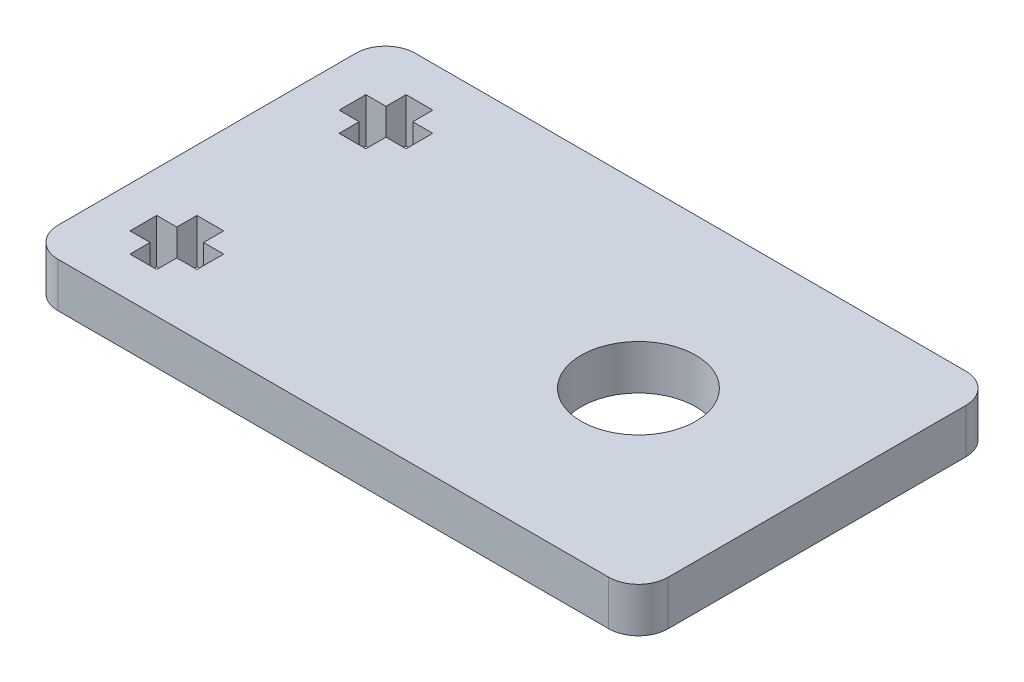
from build123d import *

# Parameters (mm, degrees)
SKETCH1_R           = 3.85
SKETCH1_R_2         = 2.25
BOSS_EXTRUDE1_DEPTH = 3
FILLET1_R           = 2
SKETCH2_W           = 35.37250713
SKETCH2_H           = 42.722638482
CUT_EXTRUDE1_DEPTH  = 10
FILLET2_R           = 2


with BuildPart() as part:
    # Sketch1 → Boss-Extrude1 (new body)
    with BuildSketch(Plane(origin=(0, 0, 0), x_dir=(1, 0, 0), z_dir=(0, 1, 0))):
        Polygon((-29, -12), (29, -12), (29, -6), (21.6, -6), (21.6, 6), (29, 6), (29, 12), (-29, 12), align=None)
        Circle(SKETCH1_R, mode=Mode.SUBTRACT)
        with Locations((23.8, 9)):
            Circle(SKETCH1_R_2, mode=Mode.SUBTRACT)
        with Locations((23.8, -9)):
            Circle(SKETCH1_R_2, mode=Mode.SUBTRACT)
        Polygon((-21.75, -6.129437252), (-23.1, -6.129437252), (-23.1, -4.779437252), (-24.9, -4.779437252), (-24.9, -6.129437252), (-26.25, -6.129437252), (-26.25, -7.929437252), (-24.9, -7.929437252), (-24.9, -9.279437252), (-23.1, -9.279437252), (-23.1, -7.929437252), (-21.75, -7.929437252), align=None, mode=Mode.SUBTRACT)
        Polygon((-23.1, 6.129437252), (-21.75, 6.129437252), (-21.75, 7.929437252), (-23.1, 7.929437252), (-23.1, 9.279437252), (-24.9, 9.279437252), (-24.9, 7.929437252), (-26.25, 7.929437252), (-26.25, 6.129437252), (-24.9, 6.129437252), (-24.9, 4.779437252), (-23.1, 4.779437252), align=None, mode=Mode.SUBTRACT)
    extrude(amount=BOSS_EXTRUDE1_DEPTH)

    # Fillet1
    fillet1_edges = [part.edges().sort_by_distance(p)[0] for p in [
        (29, 1.5, -6),
        (21.6, 1.5, -6),
        (21.6, 1.5, 6),
        (29, 1.5, 6),
        (29, 1.5, 12),
        (-29, 1.5, 12),
        (-29, 1.5, -12),
        (29, 1.5, -12),
    ]]
    fillet(fillet1_edges, radius=FILLET1_R)

    # Sketch2 → Cut-Extrude1 (cut)
    with BuildSketch(Plane(origin=(0, 3, 0), x_dir=(1, 0, 0), z_dir=(0, 1, 0))):
        with Locations((29.686253565, -0.298599086)):
            Rectangle(SKETCH2_W, SKETCH2_H)
    extrude(amount=-CUT_EXTRUDE1_DEPTH, mode=Mode.SUBTRACT)

    # Fillet2
    fillet2_edges = [part.edges().sort_by_distance(p)[0] for p in [
        (12, 1.5, 12),
        (12, 1.5, -12),
    ]]
    fillet(fillet2_edges, radius=FILLET2_R)


solid = part.part
